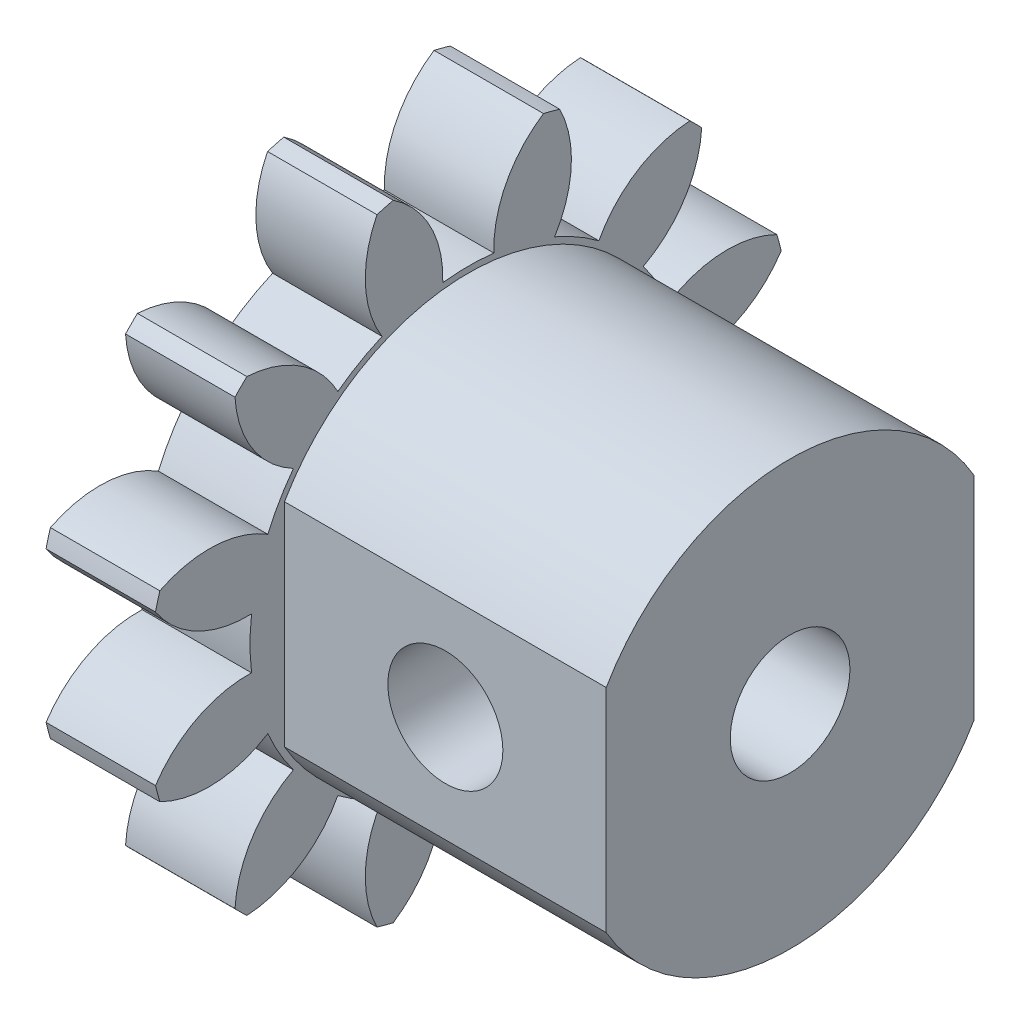
from build123d import *

# Parameters (mm, degrees)
BASPROSKE_W         = 4.7625
BASPROSKE_H         = 14
TOOTHCUT_DEPTH      = 21.36372771
TEETHCUTS_COUNT     = 12
TEETHCUTS_ANGLE     = 330
BORSKE_R            = 2.6035
BORE_DEPTH          = 50.0000508
BOSS_EXTRUDE1_DEPTH = 13.99999994
SKETCH2_R           = 2.6035
CUT_EXTRUDE1_DEPTH  = 27.882327142
SKETCH3_R           = 2.5019
CUT_EXTRUDE2_DEPTH  = 32.693338104


with BuildPart() as part:
    # BasProSke → Base-Revolve (revolve)
    with BuildSketch(Plane(origin=(0, 0, 0), x_dir=(1, 0, 0), z_dir=(0, 1, 0)), mode=Mode.PRIVATE) as base_revolve_sk:
        with Locations((2.38125, 7)):
            Rectangle(BASPROSKE_W, BASPROSKE_H)
    revolve(base_revolve_sk.sketch.rotate(Axis((-10, 0, 0), (1, 0, 0)), 180), axis=Axis((-10, 0, 0), (1, 0, 0)))

    # TooCutSke → ToothCut (cut, through all)
    with BuildSketch(Plane(origin=(0, 0, 0), x_dir=(0, 0, -1), z_dir=(1, 0, 0))):
        with BuildLine():
            ThreePointArc((1.111908866, 9.433698091), (0, 9.499), (-1.111908866, 9.433698091))
            ThreePointArc((-1.111908866, 9.433698091), (-1.651516138, 11.821129337), (-3.298149691, 13.632096456))
            ThreePointArc((-3.298149691, 13.632096456), (0, 14.0254), (3.298149691, 13.632096456))
            ThreePointArc((3.298149691, 13.632096456), (1.651516138, 11.821129337), (1.111908866, 9.433698091))
        make_face()
    toothcut = extrude(amount=TOOTHCUT_DEPTH, mode=Mode.SUBTRACT)

    # TeethCuts: ToothCut ×12 about axis
    teethcuts_axis = Axis((-10, 0, 0), (1, 0, 0))
    for i in range(1, TEETHCUTS_COUNT):
        add(toothcut.rotate(teethcuts_axis, i * TEETHCUTS_ANGLE / (TEETHCUTS_COUNT - 1)), mode=Mode.SUBTRACT)

    # BorSke → Bore (cut, symmetric)
    with BuildSketch(Plane(origin=(0, 0, 0), x_dir=(0, 0, -1), z_dir=(1, 0, 0))):
        with Locations(Location((0, 0, 0), (0, 0, 180))):
            Circle(BORSKE_R)
    extrude(amount=BORE_DEPTH, both=True, mode=Mode.SUBTRACT)

    # Sketch1 → Boss-Extrude1 (add)
    with BuildSketch(Plane(origin=(4.7625, 0, 0), x_dir=(0, 0, -1), z_dir=(1, 0, 0))):
        with BuildLine():
            Line((-8, 4.618802154), (-8, -4.618802154))
            ThreePointArc((-8, -4.618802154), (0, -9.237604307), (8, -4.618802154))
            Line((8, -4.618802154), (8, 4.618802154))
            ThreePointArc((8, 4.618802154), (0, 9.237604307), (-8, 4.618802154))
        make_face()
    extrude(amount=BOSS_EXTRUDE1_DEPTH)

    # Sketch2 → Cut-Extrude1 (cut, through all)
    with BuildSketch(Plane(origin=(18.76249994, 0, 0), x_dir=(0, 0, -1), z_dir=(1, 0, 0))):
        Circle(SKETCH2_R)
    extrude(amount=-CUT_EXTRUDE1_DEPTH, mode=Mode.SUBTRACT)

    # Sketch3 → Cut-Extrude2 (cut, through all)
    with BuildSketch(Plane.XY.offset(8)):
        with Locations((11.76249997, 0)):
            Circle(SKETCH3_R)
    extrude(amount=-CUT_EXTRUDE2_DEPTH, mode=Mode.SUBTRACT)


solid = part.part
